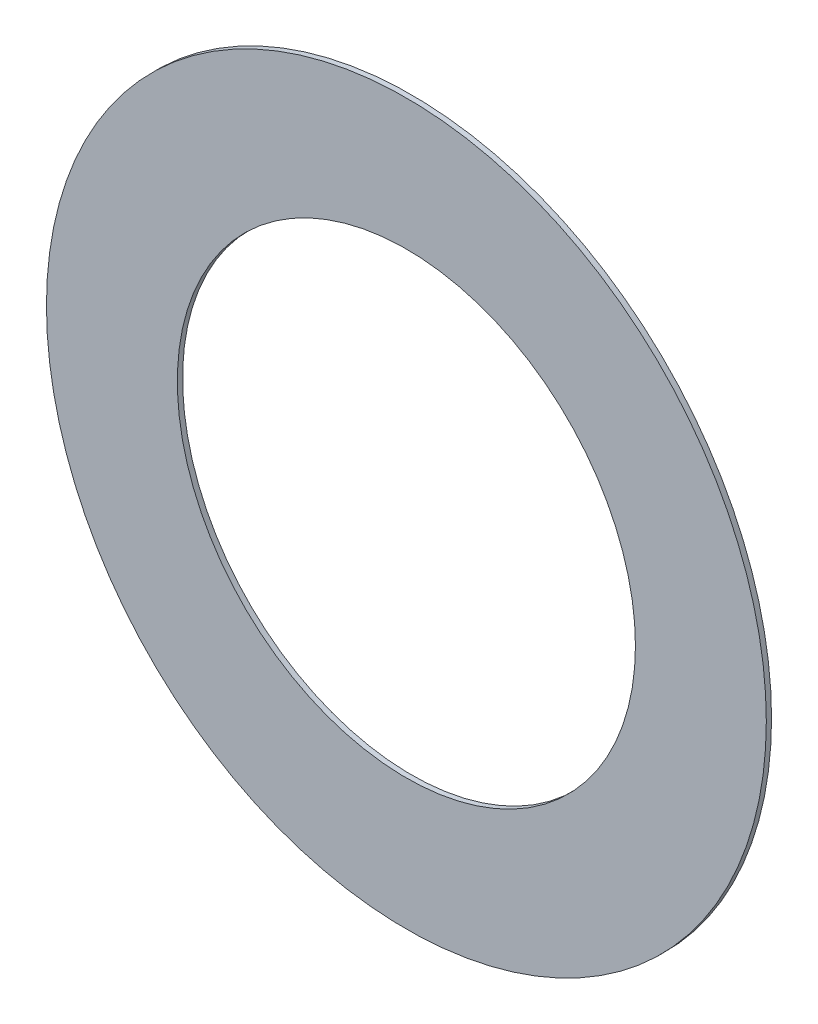
from build123d import *

# Parameters (mm, degrees)
SKETCH1_R           = 17.4625
SKETCH1_R_2         = 11.1125
BOSS_EXTRUDE1_DEPTH = 0.254


with BuildPart() as part:
    # Sketch1 → Boss-Extrude1 (new body)
    with BuildSketch(Plane.XY):
        Circle(SKETCH1_R)
        Circle(SKETCH1_R_2, mode=Mode.SUBTRACT)
    extrude(amount=BOSS_EXTRUDE1_DEPTH)


solid = part.part
